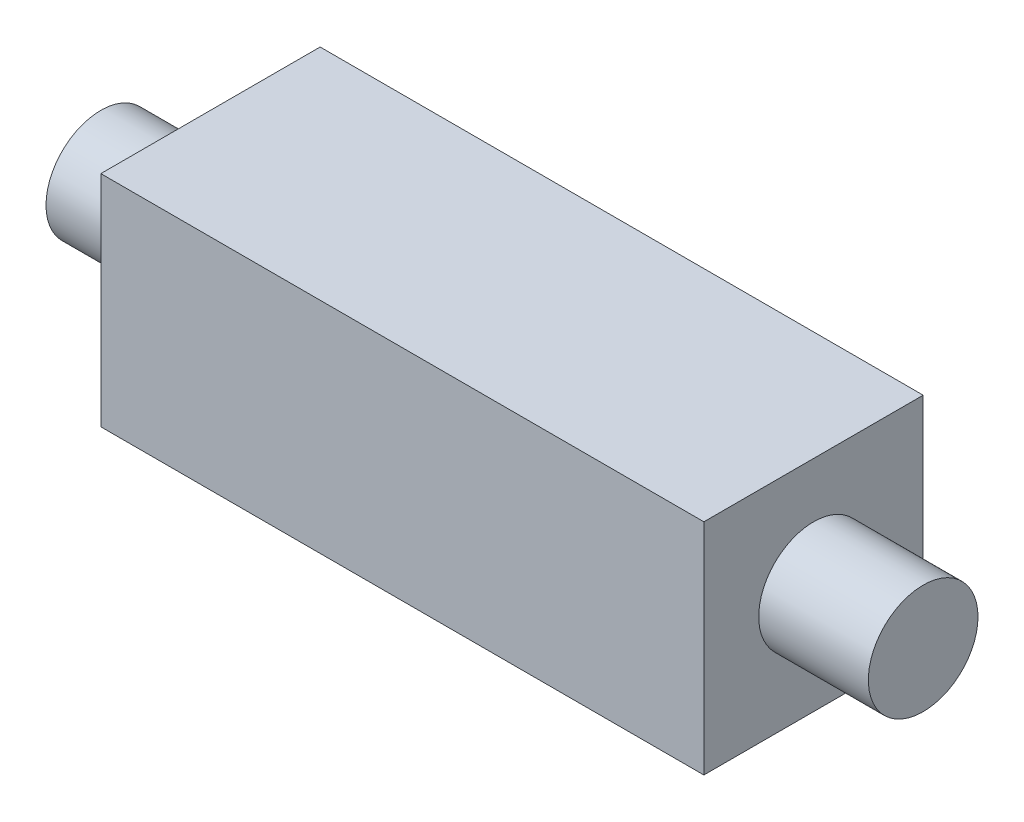
from build123d import *

# Parameters (mm, degrees)
SKETCH1_W           = 11
SKETCH1_H           = 4
BOSS_EXTRUDE1_DEPTH = 4
SKETCH2_R           = 1
BOSS_EXTRUDE2_DEPTH = 2
SKETCH3_R           = 1
BOSS_EXTRUDE3_DEPTH = 2


with BuildPart() as part:
    # Sketch1 → Boss-Extrude1 (new body)
    with BuildSketch(Plane(origin=(0, 0, 0), x_dir=(1, 0, 0), z_dir=(0, 1, 0))):
        Rectangle(SKETCH1_W, SKETCH1_H)
    extrude(amount=BOSS_EXTRUDE1_DEPTH)

    # Sketch2 → Boss-Extrude2 (add)
    with BuildSketch(Plane(origin=(5.5, 0, 0), x_dir=(0, 0, -1), z_dir=(1, 0, 0))):
        with Locations((0, 2)):
            Circle(SKETCH2_R)
    extrude(amount=BOSS_EXTRUDE2_DEPTH)

    # Sketch3 → Boss-Extrude3 (add)
    with BuildSketch(Plane.ZY.offset(5.5)):
        with Locations((0, 2)):
            Circle(SKETCH3_R)
    extrude(amount=BOSS_EXTRUDE3_DEPTH)


solid = part.part
